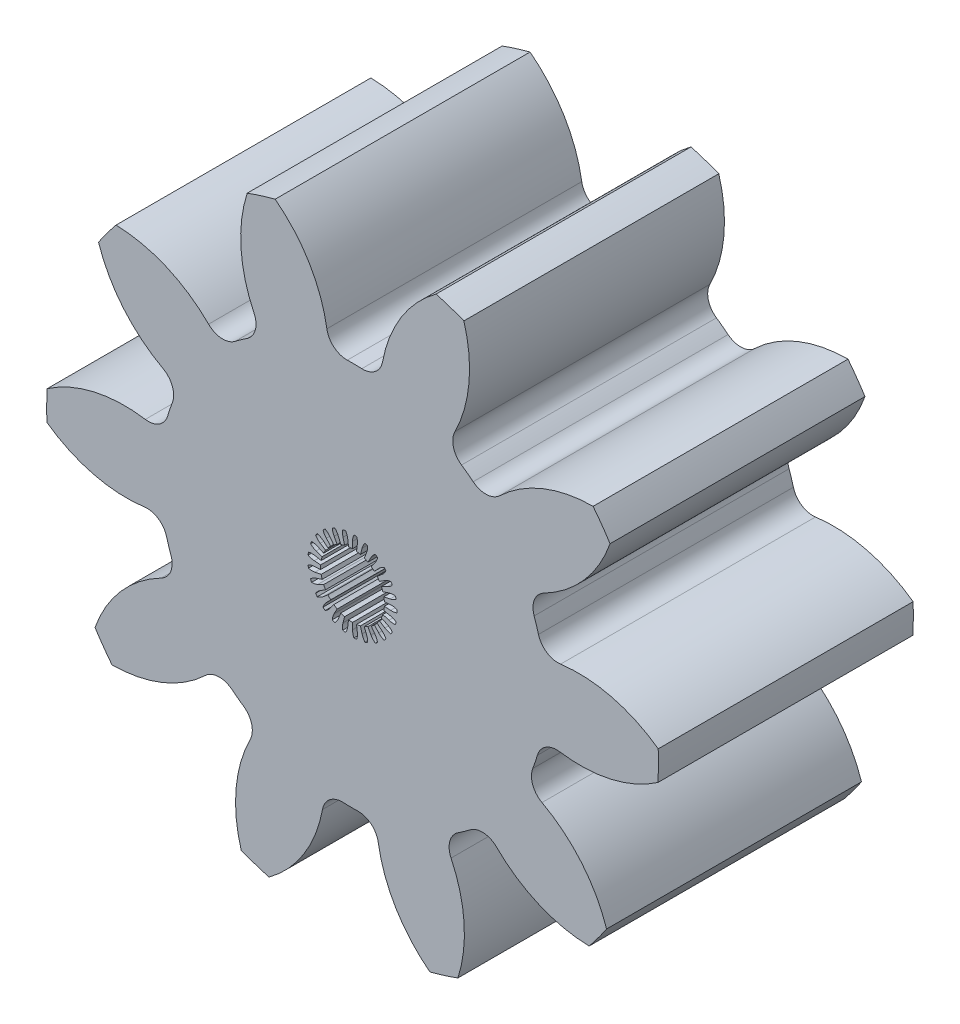
from build123d import *

# Parameters (mm, degrees)
SKETCH3_R          = 15.24
GEARBODY_DEPTH     = 12.7
TOOTHCUT_DEPTH     = 13.7
CIRPATTERN1_COUNT  = 10
CUT_EXTRUDE1_DEPTH = 13.7
CIRPATTERN2_COUNT  = 25
SKETCH5_R          = 1.589384001
CUT_EXTRUDE2_DEPTH = 13.7


with BuildPart() as part:
    # Sketch3 → gearBody (new body)
    with BuildSketch(Plane.XY):
        Circle(SKETCH3_R)
    extrude(amount=GEARBODY_DEPTH)

    # Sketch2 → toothCut (cut, through all)
    with BuildSketch(Plane.XY):
        with BuildLine():
            ThreePointArc((8.978148959, -3.402334891), (9.099733091, -3.062335565), (9.208446704, -2.718004919))
            ThreePointArc((9.208446704, -2.718004919), (9.633677899, -2.154183003), (10.324904213, -2.009535477))
            ThreePointArc((10.324904213, -2.009535477), (14.577189645, -1.27852495), (17.531773304, 1.865794244))
            ThreePointArc((17.531773304, 1.865794244), (16.709927513, -5.623396291), (12.836674632, -12.085695996))
            ThreePointArc((12.836674632, -12.085695996), (12.384259618, -7.794818645), (9.439116174, -4.64165549))
            ThreePointArc((9.439116174, -4.64165549), (8.975980875, -4.108530348), (8.978148959, -3.402334891))
        make_face()
    toothcut = extrude(amount=TOOTHCUT_DEPTH, mode=Mode.SUBTRACT)

    # CirPattern1: toothCut ×10 about axis
    cirpattern1_axis = Axis((0, 0, 0), (0, 0, 1))
    for i in range(1, CIRPATTERN1_COUNT):
        add(toothcut.rotate(cirpattern1_axis, i * 360 / CIRPATTERN1_COUNT), mode=Mode.SUBTRACT)

    # Sketch4 → Cut-Extrude1 (cut, through all)
    with BuildSketch(Plane.XY.offset(12.7)):
        with BuildLine():
            Line((0, 0), (1.574982088, 0.198966508))
            ThreePointArc((1.574982088, 0.198966508), (1.580454619, 0.149396947), (1.584367431, 0.09967995))
            Line((1.584367431, 0.09967995), (1.901240918, 0.11961594))
            ThreePointArc((1.901240918, 0.11961594), (2.06403672, 0.112163279), (2.22140333, 0.069810412))
            ThreePointArc((2.22140333, 0.069810412), (2.2225, 0), (2.22140333, -0.069810412))
            ThreePointArc((2.22140333, -0.069810412), (2.06403672, -0.112163279), (1.901240918, -0.11961594))
            Line((1.901240918, -0.11961594), (1.584367431, -0.09967995))
            ThreePointArc((1.584367431, -0.09967995), (1.580454619, -0.149396947), (1.574982088, -0.198966508))
            Line((1.574982088, -0.198966508), (0, 0))
        make_face()
    cut_extrude1 = extrude(amount=-CUT_EXTRUDE1_DEPTH, mode=Mode.SUBTRACT)

    # CirPattern2: Cut-Extrude1 ×25 about axis
    cirpattern2_axis = Axis((-0.001232738, 0, 0), (0, 0, 1))
    for i in range(1, CIRPATTERN2_COUNT):
        add(cut_extrude1.rotate(cirpattern2_axis, i * 360 / CIRPATTERN2_COUNT), mode=Mode.SUBTRACT)

    # Sketch5 → Cut-Extrude2 (cut, through all)
    with BuildSketch(Plane.XY.offset(12.7)):
        with Locations((-0.002455755, -0.000154503)):
            Circle(SKETCH5_R)
    extrude(amount=-CUT_EXTRUDE2_DEPTH, mode=Mode.SUBTRACT)


solid = part.part
